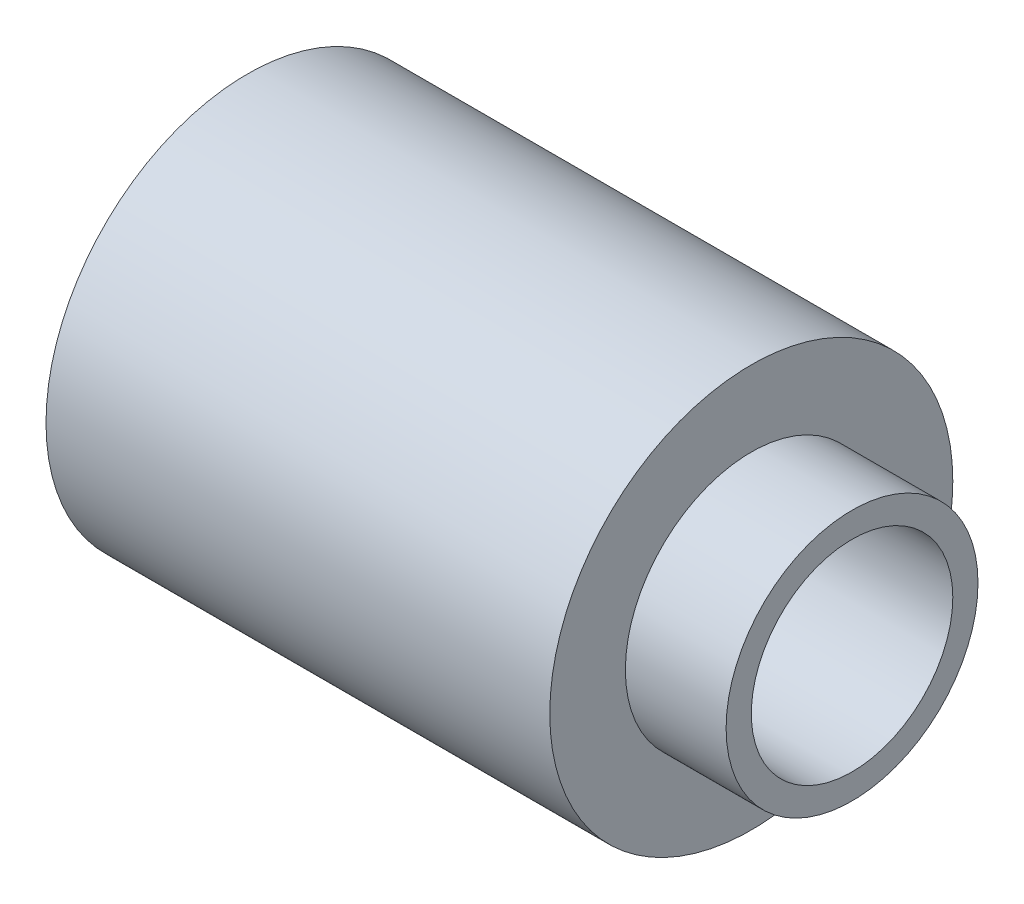
from build123d import *

# Parameters (mm, degrees)
SKETCH1_R           = 4
SKETCH1_R_2         = 2
BOSS_EXTRUDE1_DEPTH = 10
SKETCH2_R           = 2.5
SKETCH2_R_2         = 2
BOSS_EXTRUDE2_DEPTH = 2


with BuildPart() as part:
    # Sketch1 → Boss-Extrude1 (new body)
    with BuildSketch(Plane(origin=(0, 0, 0), x_dir=(0, 0, -1), z_dir=(1, 0, 0))):
        Circle(SKETCH1_R)
        Circle(SKETCH1_R_2, mode=Mode.SUBTRACT)
    extrude(amount=BOSS_EXTRUDE1_DEPTH)

    # Sketch2 → Boss-Extrude2 (add)
    with BuildSketch(Plane(origin=(10, 0, 0), x_dir=(0, 0, -1), z_dir=(1, 0, 0))):
        Circle(SKETCH2_R)
        Circle(SKETCH2_R_2, mode=Mode.SUBTRACT)
    extrude(amount=BOSS_EXTRUDE2_DEPTH)


solid = part.part
